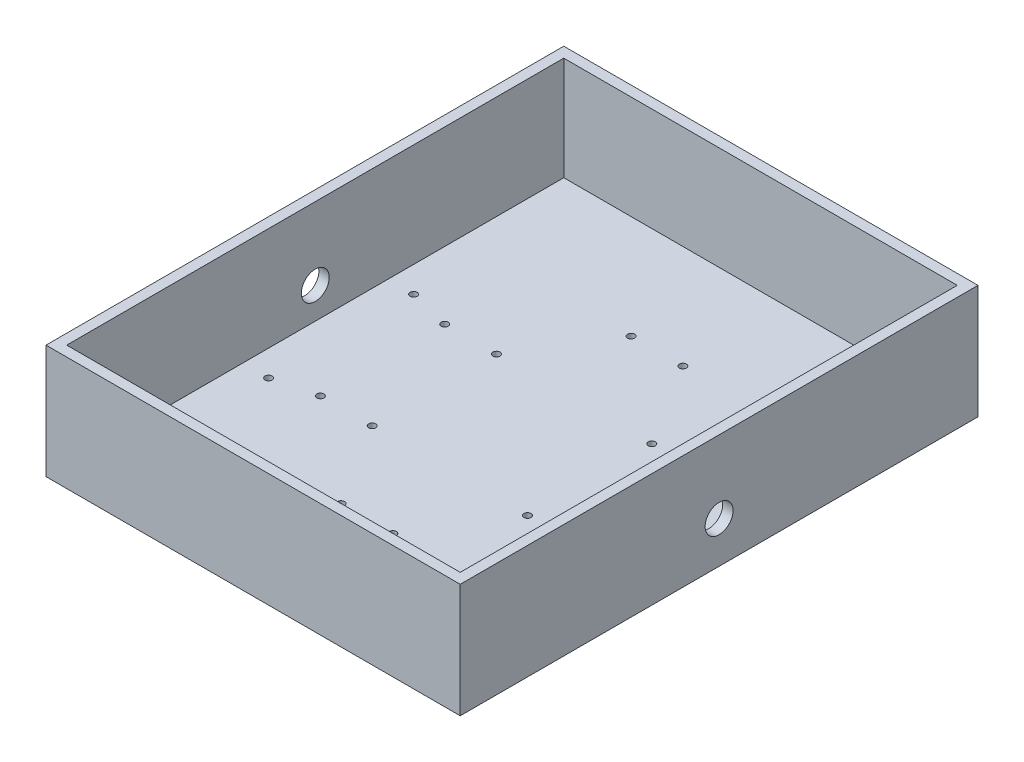
from build123d import *

# Parameters (mm, degrees)
SKETCH1_W               = 190
SKETCH1_H               = 50
BOSS_EXTRUDE1_DEPTH     = 120
SHELL1_T                = 5
SKETCH2_R               = 1.7
CUT_EXTRUDE1_DEPTH      = 168.705098312
CUT_EXTRUDE1_DEPTH_BACK = 168.705098312
SKETCH3_R               = 6.75
CUT_EXTRUDE2_DEPTH      = 168.705098312
CUT_EXTRUDE2_DEPTH_BACK = 168.705098312


with BuildPart() as part:
    # Sketch1 → Boss-Extrude1 (new, symmetric)
    with BuildSketch(Plane.XY):
        with Locations((0, 25)):
            Rectangle(SKETCH1_W, SKETCH1_H)
    extrude(amount=BOSS_EXTRUDE1_DEPTH, both=True)

    # Shell1
    shell1_openings = [part.faces().sort_by_distance(p)[0] for p in [
        (0, 50, 0),
    ]]
    offset(amount=SHELL1_T, openings=shell1_openings, kind=Kind.INTERSECTION)

    # Sketch2 → Cut-Extrude1 (cut, two sides)
    with BuildSketch(Plane(origin=(0, 0, 0), x_dir=(1, 0, 0), z_dir=(0, 1, 0))) as cut_extrude1_sk:
        with Locations(Location((-12.5, 70, 0), (0, 0, 180))):
            Circle(SKETCH2_R)
        with Locations(Location((-37.5, 30, 0), (0, 0, 180))):
            Circle(SKETCH2_R)
        with Locations(Location((-62.5, 30, 0), (0, 0, 180))):
            Circle(SKETCH2_R)
        with Locations(Location((-82.5, 35, 0), (0, 0, 180))):
            Circle(SKETCH2_R)
        with Locations(Location((82.5, 35, 0), (0, 0, 180))):
            Circle(SKETCH2_R)
        with Locations(Location((62.5, 30, 0), (0, 0, 180))):
            Circle(SKETCH2_R)
        with Locations(Location((37.5, 30, 0), (0, 0, 180))):
            Circle(SKETCH2_R)
        with Locations(Location((12.5, 70, 0), (0, 0, 180))):
            Circle(SKETCH2_R)
        with Locations(Location((12.5, -70, 0), (0, 0, 180))):
            Circle(SKETCH2_R)
        with Locations(Location((37.5, -30, 0), (0, 0, 180))):
            Circle(SKETCH2_R)
        with Locations(Location((62.5, -30, 0), (0, 0, 180))):
            Circle(SKETCH2_R)
        with Locations(Location((82.5, -35, 0), (0, 0, 180))):
            Circle(SKETCH2_R)
        with Locations(Location((-82.5, -35, 0), (0, 0, 180))):
            Circle(SKETCH2_R)
        with Locations(Location((-62.5, -30, 0), (0, 0, 180))):
            Circle(SKETCH2_R)
        with Locations(Location((-37.5, -30, 0), (0, 0, 180))):
            Circle(SKETCH2_R)
        with Locations(Location((-12.5, -70, 0), (0, 0, 180))):
            Circle(SKETCH2_R)
    extrude(amount=CUT_EXTRUDE1_DEPTH, mode=Mode.SUBTRACT)
    extrude(cut_extrude1_sk.sketch, amount=-CUT_EXTRUDE1_DEPTH_BACK, mode=Mode.SUBTRACT)

    # Sketch3 → Cut-Extrude2 (cut, two sides)
    with BuildSketch(Plane(origin=(0, 0, 0), x_dir=(0, 0, -1), z_dir=(1, 0, 0))) as cut_extrude2_sk:
        with Locations((0, 15)):
            Circle(SKETCH3_R)
    extrude(amount=CUT_EXTRUDE2_DEPTH, mode=Mode.SUBTRACT)
    extrude(cut_extrude2_sk.sketch, amount=-CUT_EXTRUDE2_DEPTH_BACK, mode=Mode.SUBTRACT)


solid = part.part
